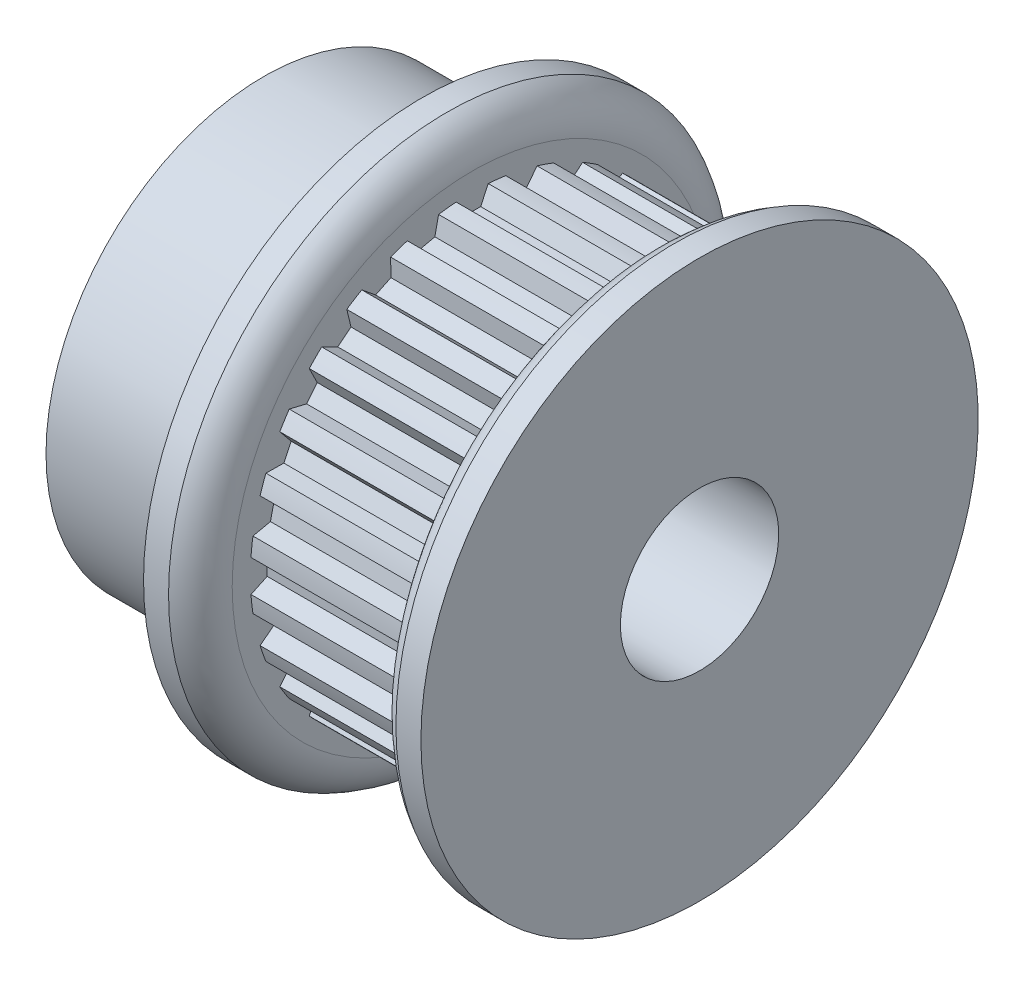
from build123d import *

# Parameters (mm, degrees)
SKETCH4_R          = 9.0551
SKETCH4_R_2        = 8.89635
CUT_EXTRUDE2_DEPTH = 7.112
CUT_EXTRUDE1_DEPTH = 7.112
CIRPATTERN1_COUNT  = 28


with BuildPart() as part:
    # Sketch1 → Revolve1 (revolve)
    with BuildSketch(Plane.XY, mode=Mode.PRIVATE) as revolve1_sk:
        with BuildLine():
            Line((-8.7376, 3.175), (8.7376, 3.175))
            Line((8.7376, 3.175), (8.7376, 11.176))
            Line((8.7376, 11.176), (7.7343, 11.176))
            ThreePointArc((7.7343, 11.176), (7.003726949, 10.549537058), (6.731, 9.6266))
            Line((6.731, 9.6266), (6.731, 9.0551))
            Line((6.731, 9.0551), (-0.381, 9.0551))
            Line((-0.381, 9.0551), (-0.381, 9.6266))
            ThreePointArc((-0.381, 9.6266), (-0.653726949, 10.549537058), (-1.3843, 11.176))
            Line((-1.3843, 11.176), (-2.3876, 11.176))
            Line((-2.3876, 11.176), (-2.3876, 8.7376))
            Line((-2.3876, 8.7376), (-8.7376, 8.7376))
            Line((-8.7376, 8.7376), (-8.7376, 3.175))
        make_face()
    revolve(revolve1_sk.sketch.rotate(Axis((-8.7376, 0, 0), (1, 0, 0)), 90), axis=Axis((-8.7376, 0, 0), (1, 0, 0)))

    # Sketch4 → Cut-Extrude2 (cut)
    with BuildSketch(Plane(origin=(-0.381, 0, 0), x_dir=(0, 0, -1), z_dir=(1, 0, 0))):
        Circle(SKETCH4_R)
        Circle(SKETCH4_R_2, mode=Mode.SUBTRACT)
    extrude(amount=CUT_EXTRUDE2_DEPTH, mode=Mode.SUBTRACT)

    # Sketch3 → Cut-Extrude1 (cut)
    with BuildSketch(Plane(origin=(-0.381, 0, 0), x_dir=(0, 0, -1), z_dir=(1, 0, 0))):
        with BuildLine():
            Line((-0.643388094, 8.873054439), (-0.340062676, 8.222570981))
            Line((-0.340062676, 8.222570981), (0.340062676, 8.222570981))
            Line((0.340062676, 8.222570981), (0.643388094, 8.873054439))
            ThreePointArc((0.643388094, 8.873054439), (0, 8.89635), (-0.643388094, 8.873054439))
        make_face()
    cut_extrude1 = extrude(amount=CUT_EXTRUDE1_DEPTH, mode=Mode.SUBTRACT)

    # CirPattern1: Cut-Extrude1 ×28 about axis
    cirpattern1_axis = Axis((0, 0, 0), (1, 0, 0))
    for i in range(1, CIRPATTERN1_COUNT):
        add(cut_extrude1.rotate(cirpattern1_axis, i * 360 / CIRPATTERN1_COUNT), mode=Mode.SUBTRACT)


solid = part.part
